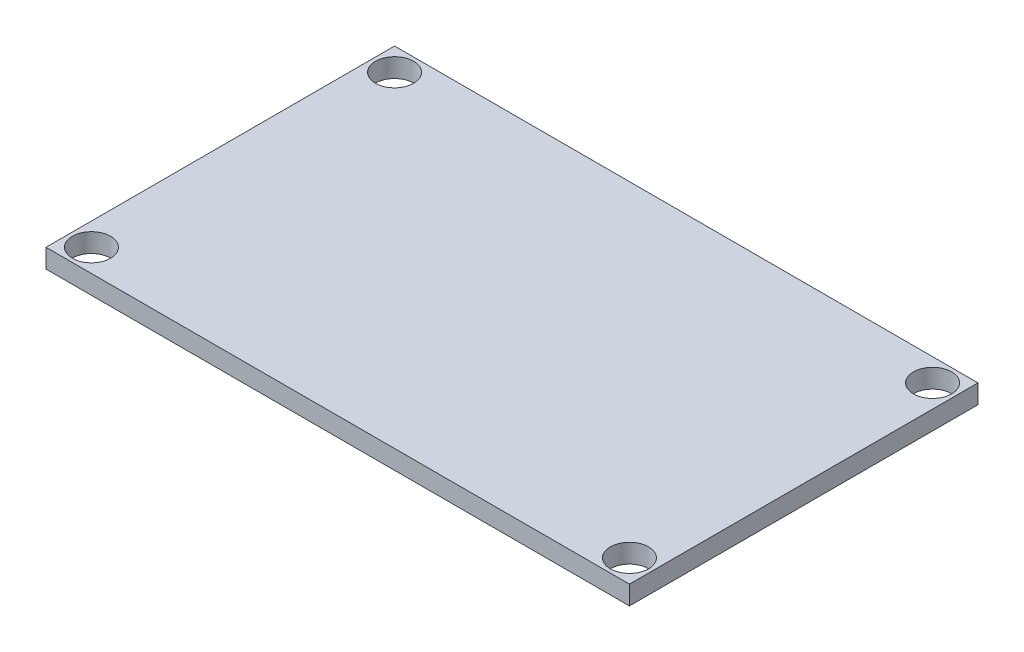
from build123d import *

# Parameters (mm, degrees)
SKETCH1_W           = 48.895
SKETCH1_H           = 29.21
SKETCH1_R           = 1.599999975
BOSS_EXTRUDE1_DEPTH = 1.5875


with BuildPart() as part:
    # Sketch1 → Boss-Extrude1 (new body)
    with BuildSketch(Plane(origin=(0, 0, 0), x_dir=(1, 0, 0), z_dir=(0, 1, 0))):
        Rectangle(SKETCH1_W, SKETCH1_H)
        with Locations((-22.5425, 12.7)):
            Circle(SKETCH1_R, mode=Mode.SUBTRACT)
        with Locations((-22.5425, -12.7)):
            Circle(SKETCH1_R, mode=Mode.SUBTRACT)
        with Locations((22.5425, -12.7)):
            Circle(SKETCH1_R, mode=Mode.SUBTRACT)
        with Locations((22.5425, 12.7)):
            Circle(SKETCH1_R, mode=Mode.SUBTRACT)
    extrude(amount=BOSS_EXTRUDE1_DEPTH)


solid = part.part
